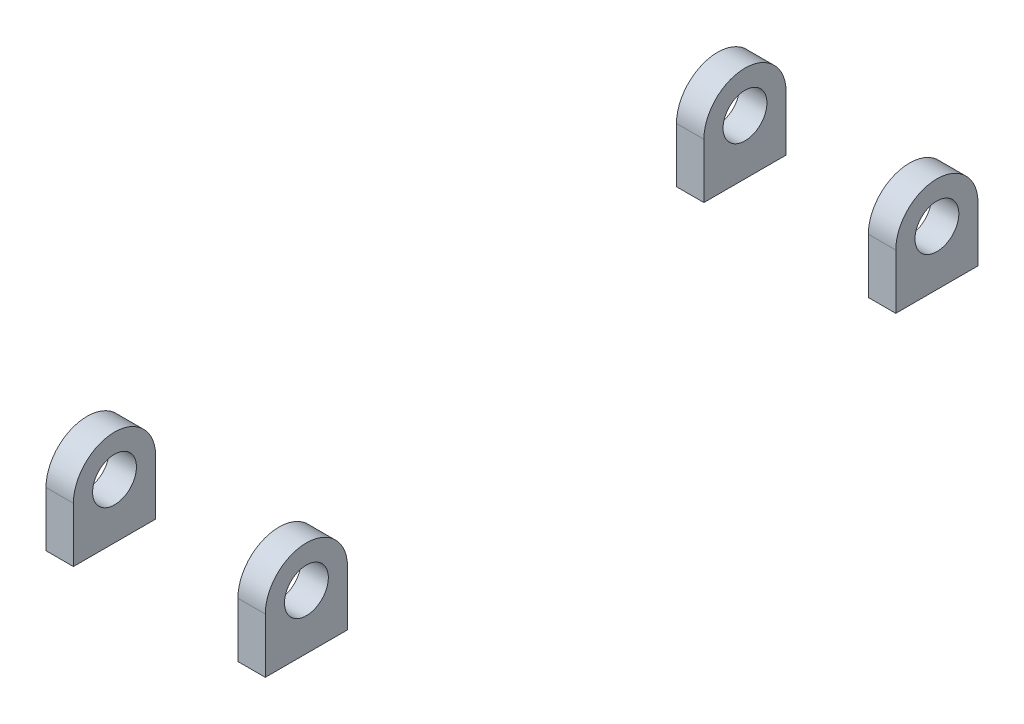
from build123d import *

# Parameters (mm, degrees)
SKETCH1_W             = 5
SKETCH1_H             = 15
BOSS_EXTRUDE1_DEPTH   = 20
BOSS_EXTRUDE1_2_DEPTH = 20
BOSS_EXTRUDE1_3_DEPTH = 20
BOSS_EXTRUDE1_4_DEPTH = 20
SKETCH2_R             = 4
CUT_EXTRUDE1_DEPTH    = 41


with BuildPart() as part:
    # Sketch1 → Boss-Extrude1 (new body)
    with BuildSketch(Plane(origin=(0, 0, 0), x_dir=(1, 0, 0), z_dir=(0, 1, 0))):
        with Locations((17.5, -76.336474884)):
            Rectangle(SKETCH1_W, SKETCH1_H)
    extrude(amount=BOSS_EXTRUDE1_DEPTH)


with BuildPart() as body_2:
    # Sketch1 → Boss-Extrude1 2 (new body)
    with BuildSketch(Plane(origin=(0, 0, 0), x_dir=(1, 0, 0), z_dir=(0, 1, 0))):
        with Locations((-17.5, -76.336474884)):
            Rectangle(SKETCH1_W, SKETCH1_H)
    extrude(amount=BOSS_EXTRUDE1_2_DEPTH)


with BuildPart() as body_3:
    # Sketch1 → Boss-Extrude1 3 (new body)
    with BuildSketch(Plane(origin=(0, 0, 0), x_dir=(1, 0, 0), z_dir=(0, 1, 0))):
        with Locations((-17.5, 38.663525116)):
            Rectangle(SKETCH1_W, SKETCH1_H)
    extrude(amount=BOSS_EXTRUDE1_3_DEPTH)


with BuildPart() as body_4:
    # Sketch1 → Boss-Extrude1 4 (new body)
    with BuildSketch(Plane(origin=(0, 0, 0), x_dir=(1, 0, 0), z_dir=(0, 1, 0))):
        with Locations((17.5, 38.663525116)):
            Rectangle(SKETCH1_W, SKETCH1_H)
    extrude(amount=BOSS_EXTRUDE1_4_DEPTH)


with BuildPart() as cut_extrude1_tool:
    # Sketch2 → Cut-Extrude1 (new body, through all)
    with BuildSketch(Plane.ZY.offset(20)):
        with Locations((-38.663525116, 10)):
            Circle(SKETCH2_R)
        with Locations((76.336474884, 10)):
            Circle(SKETCH2_R)
        with BuildLine():
            Line((-46.163525116, 10), (-46.163525116, 20))
            Line((-46.163525116, 20), (-31.163525116, 20))
            Line((-31.163525116, 20), (-31.163525116, 10))
            ThreePointArc((-31.163525116, 10), (-38.663525116, 17.5), (-46.163525116, 10))
        make_face()
        with BuildLine():
            Line((68.836474884, 10), (68.836474884, 20))
            Line((68.836474884, 20), (83.836474884, 20))
            Line((83.836474884, 20), (83.836474884, 10))
            ThreePointArc((83.836474884, 10), (76.336474884, 17.5), (68.836474884, 10))
        make_face()
    extrude(amount=-CUT_EXTRUDE1_DEPTH)


with BuildPart() as part_1:
    add(part.part)

    # Cut-Extrude1: cut by cut_extrude1_tool
    add(cut_extrude1_tool.part, mode=Mode.SUBTRACT)


with BuildPart() as body_2_1:
    add(body_2.part)

    # Cut-Extrude1: cut by cut_extrude1_tool
    add(cut_extrude1_tool.part, mode=Mode.SUBTRACT)


with BuildPart() as body_3_1:
    add(body_3.part)

    # Cut-Extrude1: cut by cut_extrude1_tool
    add(cut_extrude1_tool.part, mode=Mode.SUBTRACT)


with BuildPart() as body_4_1:
    add(body_4.part)

    # Cut-Extrude1: cut by cut_extrude1_tool
    add(cut_extrude1_tool.part, mode=Mode.SUBTRACT)


solid = Compound([part_1.part, body_2_1.part, body_3_1.part, body_4_1.part])
